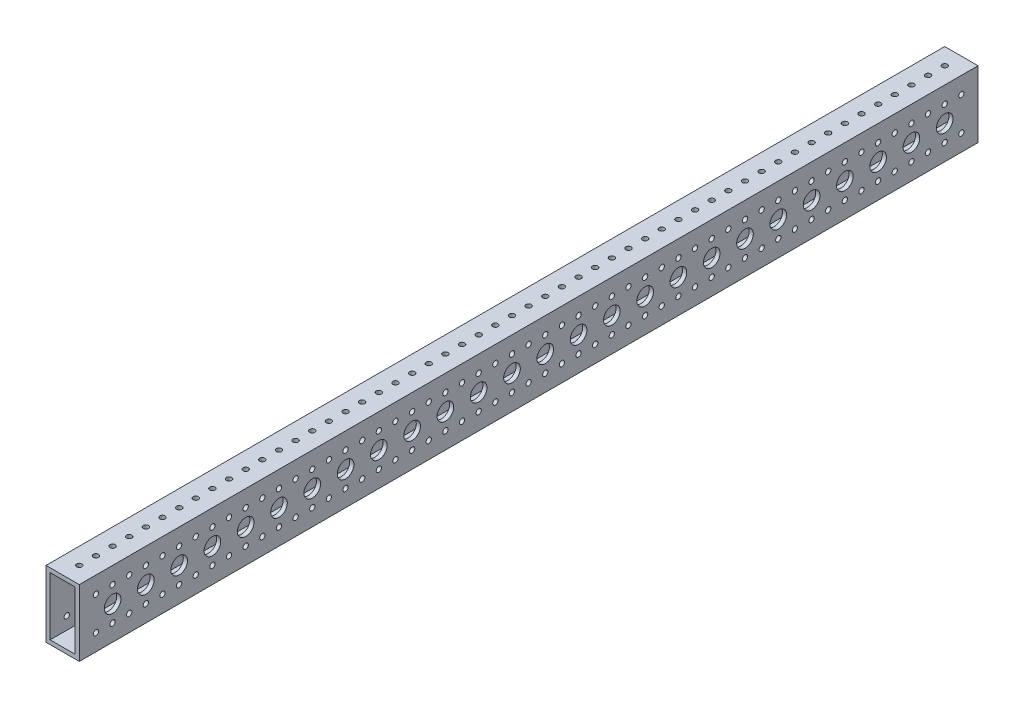
from build123d import *

# Parameters (mm, degrees)
SKETCH1_W                   = 25.4
SKETCH1_H                   = 50.8
BOSS_EXTRUDE1_DEPTH         = 685.8
SHELL1_T                    = -3.175
F_21_0_159_DIAMETER_HOLE1_D = 4.0386
LPATTERN1_COUNT             = 53
LPATTERN1_PITCH             = 12.7
F_21_0_159_DIAMETER_HOLE2_D = 4.0386
LPATTERN2_COUNT             = 53
LPATTERN2_PITCH             = 12.7
LPATTERN2_COUNT_DIR2        = 2
LPATTERN2_PITCH_DIR2        = 25.4
F_1_2_0_5_DIAMETER_HOLE1_D  = 12.7
LPATTERN3_COUNT             = 26
LPATTERN3_PITCH             = 25.4


with BuildPart() as part:
    # Sketch1 → Boss-Extrude1 (new body)
    with BuildSketch(Plane.XY):
        Rectangle(SKETCH1_W, SKETCH1_H)
    extrude(amount=BOSS_EXTRUDE1_DEPTH)

    # Shell1
    shell1_openings = [part.faces().sort_by_distance(p)[0] for p in [
        (0, 0, 685.8),
        (0, 0, 0),
    ]]
    offset(amount=SHELL1_T, openings=shell1_openings, kind=Kind.INTERSECTION)

    # #21 (0.159) Diameter Hole1 (through all)
    with Locations(Plane(origin=(0, 25.4, 0), x_dir=(1, 0, 0), z_dir=(0, 1, 0))):
        with Locations((0, -12.7)):
            f_21_0_159_diameter_hole1 = Hole(F_21_0_159_DIAMETER_HOLE1_D / 2)

    # LPattern1: #21 (0.159) Diameter Hole1 ×53
    with Locations(*[(0, 0, i * LPATTERN1_PITCH) for i in range(1, LPATTERN1_COUNT)]):
        add(f_21_0_159_diameter_hole1, mode=Mode.SUBTRACT)

    # #21 (0.159) Diameter Hole2 (through all)
    with Locations(Plane.ZY.offset(12.7)):
        with Locations((12.7, 12.7)):
            f_21_0_159_diameter_hole2 = Hole(F_21_0_159_DIAMETER_HOLE2_D / 2)

    # LPattern2: 21 _0.159_ Diameter Hole2 53 × 2
    with Locations(*[(0, -j * LPATTERN2_PITCH_DIR2, i * LPATTERN2_PITCH) for i in range(LPATTERN2_COUNT) for j in range(LPATTERN2_COUNT_DIR2) if (i, j) != (0, 0)]):
        add(f_21_0_159_diameter_hole2, mode=Mode.SUBTRACT)

    # 1/2 (0.5) Diameter Hole1 (through all)
    with Locations(Plane.ZY.offset(12.7)):
        with Locations((25.4, 0)):
            f_1_2_0_5_diameter_hole1 = Hole(F_1_2_0_5_DIAMETER_HOLE1_D / 2)

    # LPattern3: 1/2 (0.5) Diameter Hole1 ×26
    with Locations(*[(0, 0, i * LPATTERN3_PITCH) for i in range(1, LPATTERN3_COUNT)]):
        add(f_1_2_0_5_diameter_hole1, mode=Mode.SUBTRACT)


solid = part.part
